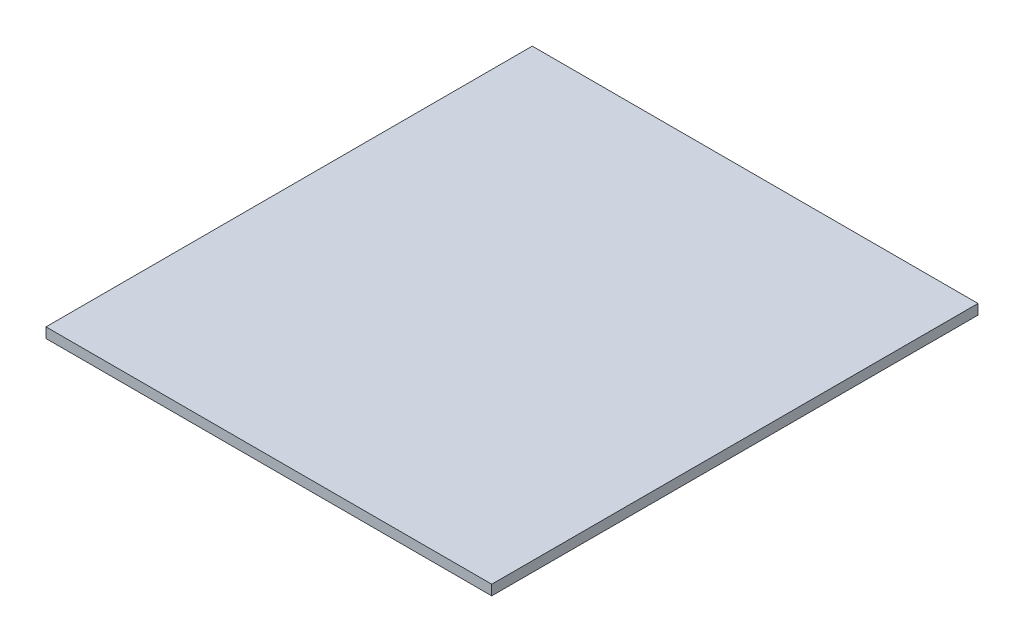
from build123d import *

# Parameters (mm, degrees)
SKETCH1_W           = 88
SKETCH1_H           = 96
BOSS_EXTRUDE1_DEPTH = 2


with BuildPart() as part:
    # Sketch1 → Boss-Extrude1 (new body)
    with BuildSketch(Plane(origin=(0, 0, 0), x_dir=(1, 0, 0), z_dir=(0, 1, 0))):
        Rectangle(SKETCH1_W, SKETCH1_H)
    extrude(amount=BOSS_EXTRUDE1_DEPTH)


solid = part.part
